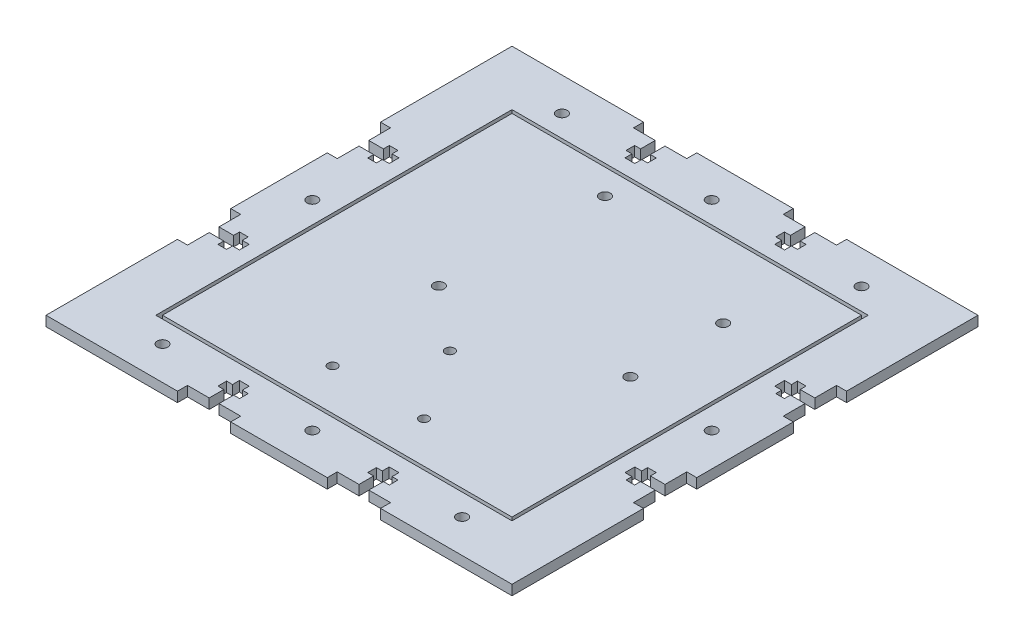
from build123d import *

# Parameters (mm, degrees)
SKETCH2_W           = 140
SKETCH2_H           = 140
SKETCH2_R           = 1.6
SKETCH2_R_2         = 1.4
BOSS_EXTRUDE2_DEPTH = 3
SKETCH3_W           = 16
SKETCH3_H           = 3
SKETCH3_W_2         = 3
SKETCH3_H_2         = 16
CUT_EXTRUDE2_DEPTH  = 3
CUT_EXTRUDE3_DEPTH  = 3
SKETCH5_W           = 107
SKETCH5_H           = 107
SKETCH5_W_2         = 105
SKETCH5_H_2         = 105
CUT_EXTRUDE5_DEPTH  = 3


with BuildPart() as part:
    # Sketch2 → Boss-Extrude2 (new body)
    with BuildSketch(Plane(origin=(0, 0, 0), x_dir=(1, 0, 0), z_dir=(0, 1, 0))):
        Rectangle(SKETCH2_W, SKETCH2_H)
        with Locations((-17.011581703, 44.949159058)):
            Circle(SKETCH2_R, mode=Mode.SUBTRACT)
        with Locations((-18.611581703, -3.350840942)):
            Circle(SKETCH2_R, mode=Mode.SUBTRACT)
        with Locations((33.788418297, 29.649159058)):
            Circle(SKETCH2_R, mode=Mode.SUBTRACT)
        with Locations((33.788418297, 1.749159058)):
            Circle(SKETCH2_R, mode=Mode.SUBTRACT)
        with Locations((0, 60)):
            Circle(SKETCH2_R, mode=Mode.SUBTRACT)
        with Locations((-60, 0)):
            Circle(SKETCH2_R, mode=Mode.SUBTRACT)
        with Locations((0, -60)):
            Circle(SKETCH2_R, mode=Mode.SUBTRACT)
        with Locations((60, 0)):
            Circle(SKETCH2_R, mode=Mode.SUBTRACT)
        with Locations((-45, 60)):
            Circle(SKETCH2_R, mode=Mode.SUBTRACT)
        with Locations((45, 60)):
            Circle(SKETCH2_R, mode=Mode.SUBTRACT)
        with Locations((-45, -60)):
            Circle(SKETCH2_R, mode=Mode.SUBTRACT)
        with Locations((45, -60)):
            Circle(SKETCH2_R, mode=Mode.SUBTRACT)
        with Locations((-0.030225379, -18.62367845)):
            Circle(SKETCH2_R_2, mode=Mode.SUBTRACT)
        with Locations((-13.780225379, -40.12367845)):
            Circle(SKETCH2_R_2, mode=Mode.SUBTRACT)
        with Locations((13.719774621, -40.12367845)):
            Circle(SKETCH2_R_2, mode=Mode.SUBTRACT)
    extrude(amount=BOSS_EXTRUDE2_DEPTH)

    # Sketch3 → Cut-Extrude2 (cut)
    with BuildSketch(Plane(origin=(0, 3, 0), x_dir=(1, 0, 0), z_dir=(0, 1, 0))):
        with Locations((-22.5, 68.5)):
            Rectangle(SKETCH3_W, SKETCH3_H)
        with Locations((-22.5, -68.5)):
            Rectangle(SKETCH3_W, SKETCH3_H)
        with Locations((22.5, -68.5)):
            Rectangle(SKETCH3_W, SKETCH3_H)
        with Locations((22.5, 68.5)):
            Rectangle(SKETCH3_W, SKETCH3_H)
        with Locations((-68.5, 22.5)):
            Rectangle(SKETCH3_W_2, SKETCH3_H_2)
        with Locations((68.5, 22.5)):
            Rectangle(SKETCH3_W_2, SKETCH3_H_2)
        with Locations((68.5, -22.5)):
            Rectangle(SKETCH3_W_2, SKETCH3_H_2)
        with Locations((-68.5, -22.5)):
            Rectangle(SKETCH3_W_2, SKETCH3_H_2)
    extrude(amount=-CUT_EXTRUDE2_DEPTH, mode=Mode.SUBTRACT)

    # Sketch4 → Cut-Extrude3 (cut)
    with BuildSketch(Plane(origin=(0, 3, 0), x_dir=(1, 0, 0), z_dir=(0, 1, 0))):
        Polygon((-23.97, 67), (-23.97, 62.6), (-25.75, 62.6), (-25.75, 60), (-23.97, 60), (-23.97, 57.92), (-21.03, 57.92), (-21.03, 60), (-19.25, 60), (-19.25, 62.6), (-21.03, 62.6), (-21.03, 67), align=None)
        Polygon((-23.97, -62.6), (-25.75, -62.6), (-25.75, -60), (-23.97, -60), (-23.97, -57.92), (-21.03, -57.92), (-21.03, -60), (-19.25, -60), (-19.25, -62.6), (-21.03, -62.6), (-21.03, -67), (-23.97, -67), align=None)
        Polygon((21.03, -60), (21.03, -57.92), (23.97, -57.92), (23.97, -60), (25.75, -60), (25.75, -62.6), (23.97, -62.6), (23.97, -67), (21.03, -67), (21.03, -62.6), (19.25, -62.6), (19.25, -60), align=None)
        Polygon((21.03, 67), (23.97, 67), (23.97, 62.6), (25.75, 62.6), (25.75, 60), (23.97, 60), (23.97, 57.92), (21.03, 57.92), (21.03, 60), (19.25, 60), (19.25, 62.6), (21.03, 62.6), align=None)
        Polygon((67, 23.97), (62.6, 23.97), (62.6, 25.75), (60, 25.75), (60, 23.97), (57.92, 23.97), (57.92, 21.03), (60, 21.03), (60, 19.25), (62.6, 19.25), (62.6, 21.03), (67, 21.03), align=None)
        Polygon((-67, 23.97), (-67, 21.03), (-62.6, 21.03), (-62.6, 19.25), (-60, 19.25), (-60, 21.03), (-57.92, 21.03), (-57.92, 23.97), (-60, 23.97), (-60, 25.75), (-62.6, 25.75), (-62.6, 23.97), align=None)
        Polygon((-67, -23.97), (-62.6, -23.97), (-62.6, -25.75), (-60, -25.75), (-60, -23.97), (-57.92, -23.97), (-57.92, -21.03), (-60, -21.03), (-60, -19.25), (-62.6, -19.25), (-62.6, -21.03), (-67, -21.03), align=None)
        Polygon((67, -23.97), (62.6, -23.97), (62.6, -25.75), (60, -25.75), (60, -23.97), (57.92, -23.97), (57.92, -21.03), (60, -21.03), (60, -19.25), (62.6, -19.25), (62.6, -21.03), (67, -21.03), align=None)
    extrude(amount=-CUT_EXTRUDE3_DEPTH, mode=Mode.SUBTRACT)

    # Sketch5 → Cut-Extrude5 (cut)
    with BuildSketch(Plane(origin=(0, 3, 0), x_dir=(1, 0, 0), z_dir=(0, 1, 0))):
        Rectangle(SKETCH5_W, SKETCH5_H)
        Rectangle(SKETCH5_W_2, SKETCH5_H_2, mode=Mode.SUBTRACT)
    extrude(amount=-CUT_EXTRUDE5_DEPTH, mode=Mode.SUBTRACT)


solid = part.part
